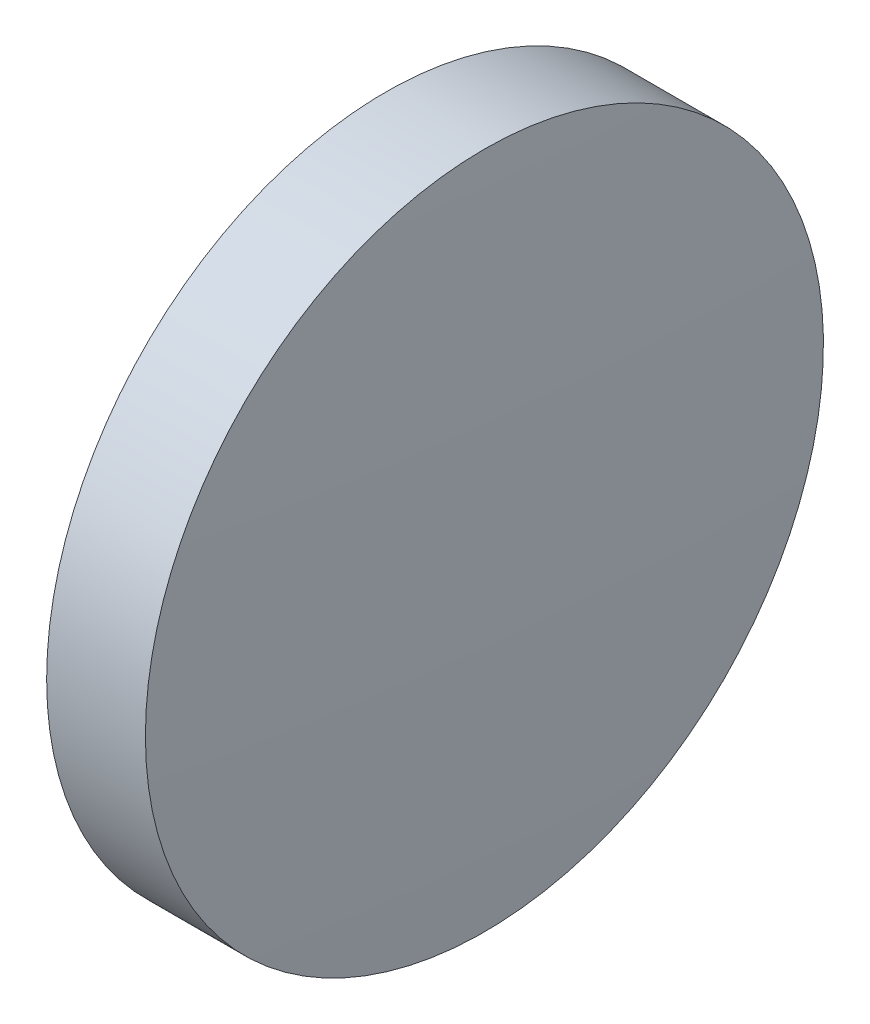
from build123d import *


with BuildPart() as part:
    # 草图1 → 旋转1 (revolve)
    with BuildSketch(Plane.XY):
        with BuildLine():
            Line((115.764555476, 65.233554926), (115.764555476, 77.933554926))
            Line((115.764555476, 77.933554926), (119.464555476, 77.933554926))
            ThreePointArc((119.464555476, 77.933554926), (119.689545017, 71.585326333), (119.764555476, 65.233554926))
            Line((119.764555476, 65.233554926), (115.764555476, 65.233554926))
        make_face()
    revolve(axis=Axis((110.165373228, 65.233554926, 0), (1, 0, 0)))


solid = part.part
